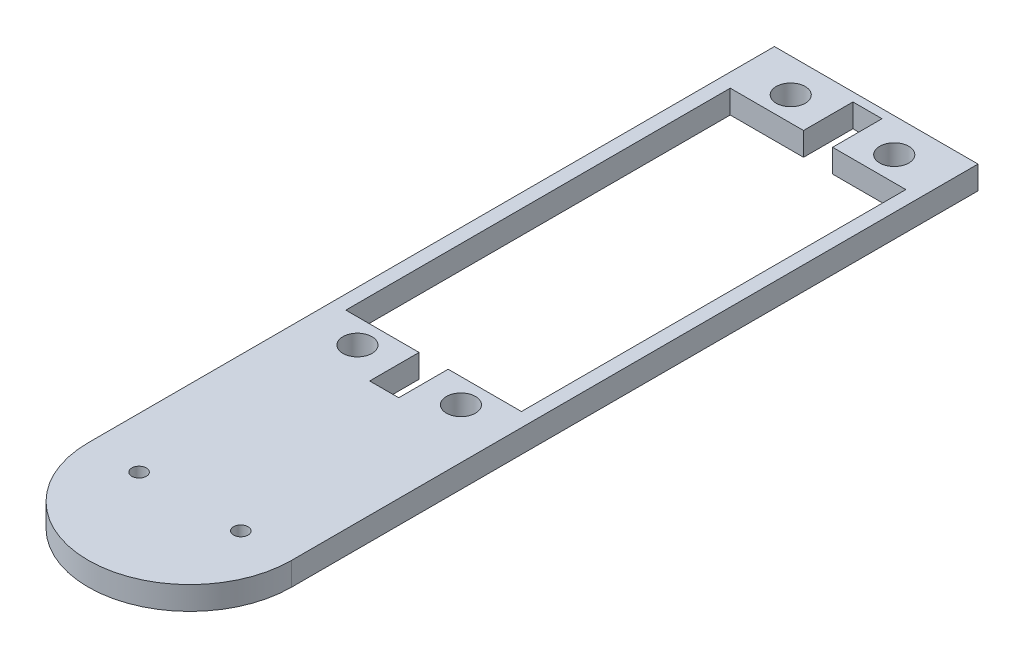
from build123d import *

# Parameters (mm, degrees)
BOSS_EXTRUDE1_DEPTH = 4
SKETCH2_R           = 1.25
CUT_EXTRUDE1_DEPTH  = 4
SKETCH6_R           = 2.5
SKETCH6_W           = 30.2
SKETCH6_H           = 66.1
CUT_EXTRUDE5_DEPTH  = 4
CUT_EXTRUDE6_DEPTH  = 4


with BuildPart() as part:
    # Sketch1 → Boss-Extrude1 (new body)
    with BuildSketch(Plane(origin=(0, 0, 0), x_dir=(1, 0, 0), z_dir=(0, 1, 0))):
        with BuildLine():
            Line((-17.5, 0), (-17.5, 118))
            Line((-17.5, 118), (17.5, 118))
            Line((17.5, 118), (17.5, 0))
            ThreePointArc((17.5, 0), (0, -17.5), (-17.5, 0))
        make_face()
    extrude(amount=BOSS_EXTRUDE1_DEPTH)

    # Sketch2 → Cut-Extrude1 (cut)
    with BuildSketch(Plane(origin=(0, 4, 0), x_dir=(1, 0, 0), z_dir=(0, 1, 0))):
        with Locations((-8.75, 0)):
            Circle(SKETCH2_R)
        with Locations((8.75, 0)):
            Circle(SKETCH2_R)
    extrude(amount=-CUT_EXTRUDE1_DEPTH, mode=Mode.SUBTRACT)

    # Sketch6 → Cut-Extrude5 (cut)
    with BuildSketch(Plane(origin=(0, 4, 0), x_dir=(1, 0, 0), z_dir=(0, 1, 0))):
        with Locations((-8.9, 37.7)):
            Circle(SKETCH6_R)
        with Locations((8.9, 37.7)):
            Circle(SKETCH6_R)
        with Locations((8.9, 112.2)):
            Circle(SKETCH6_R)
        with Locations((-8.9, 112.2)):
            Circle(SKETCH6_R)
        with Locations((0, 74.95)):
            Rectangle(SKETCH6_W, SKETCH6_H)
    extrude(amount=-CUT_EXTRUDE5_DEPTH, mode=Mode.SUBTRACT)

    # Sketch7 → Cut-Extrude6 (cut)
    with BuildSketch(Plane(origin=(0, 4, 0), x_dir=(1, 0, 0), z_dir=(0, 1, 0))):
        Polygon((0, 41.9), (-2.5, 41.9), (-2.5, 33.4), (2.5, 33.4), (2.5, 41.9), align=None)
        Polygon((2.5, 108), (0, 108), (-2.5, 108), (-2.5, 116.5), (2.5, 116.5), align=None)
    extrude(amount=-CUT_EXTRUDE6_DEPTH, mode=Mode.SUBTRACT)


solid = part.part
